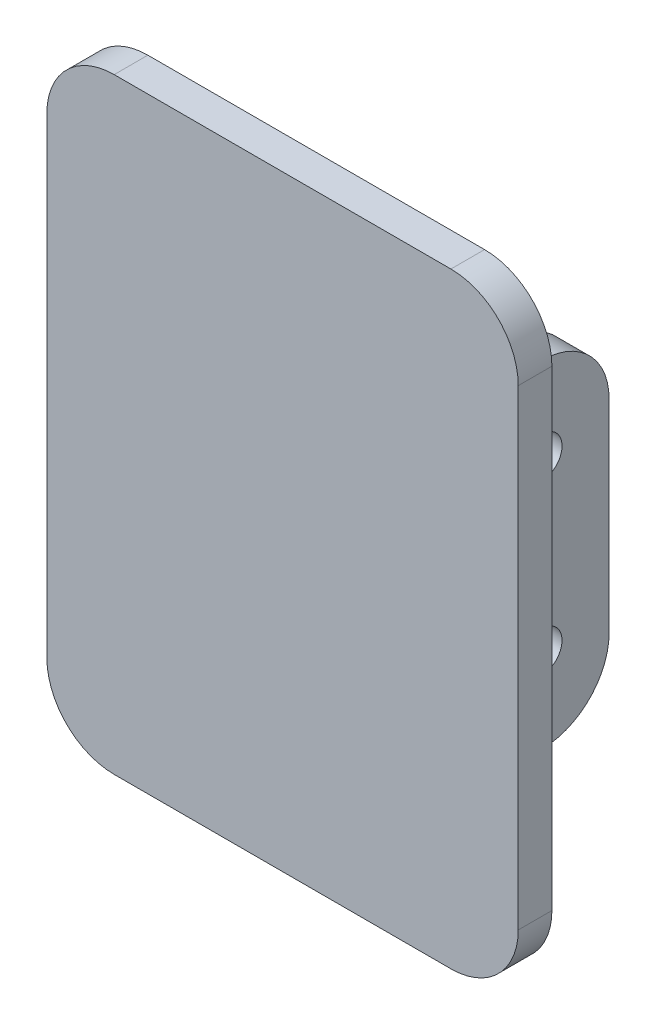
from build123d import *

# Parameters (mm, degrees)
SKETCH1_W           = 70
SKETCH1_H           = 90
BOSS_EXTRUDE1_DEPTH = 5
SKETCH3_W           = 5
SKETCH3_H           = 50
BOSS_EXTRUDE2_DEPTH = 20
SKETCH4_R           = 3
CUT_EXTRUDE1_DEPTH  = 59.5
FILLET1_R           = 3
FILLET2_R           = 10
FILLET3_R           = 10


with BuildPart() as part:
    # Sketch1 → Boss-Extrude1 (new body)
    with BuildSketch(Plane.XY):
        Rectangle(SKETCH1_W, SKETCH1_H)
    extrude(amount=BOSS_EXTRUDE1_DEPTH)

    # Sketch3 → Boss-Extrude2 (add)
    with BuildSketch(Plane(origin=(0, 0, 0), x_dir=(-1, 0, 0), z_dir=(0, 0, -1))):
        with Locations((-1, 0)):
            Rectangle(SKETCH3_W, SKETCH3_H)
        with Locations((-21, 0)):
            Rectangle(SKETCH3_W, SKETCH3_H)
    extrude(amount=BOSS_EXTRUDE2_DEPTH)

    # Sketch4 → Cut-Extrude1 (cut, through all)
    with BuildSketch(Plane(origin=(23.5, 0, 0), x_dir=(0, 0, -1), z_dir=(1, 0, 0))):
        with Locations((10, 12.5)):
            Circle(SKETCH4_R)
        with Locations((10, -12.5)):
            Circle(SKETCH4_R)
    extrude(amount=-CUT_EXTRUDE1_DEPTH, mode=Mode.SUBTRACT)

    # Fillet1
    fillet1_edges = [part.edges().sort_by_distance(p)[0] for p in [
        (21, 25, 0),
        (23.5, 0, 0),
        (21, -25, 0),
        (-1.5, 0, 0),
        (1, 25, 0),
        (1, -25, 0),
    ]]
    fillet(fillet1_edges, radius=FILLET1_R)

    # Fillet2
    fillet2_edges = [part.edges().sort_by_distance(p)[0] for p in [
        (21, 25, -20),
        (21, -25, -20),
        (1, 25, -20),
        (1, -25, -20),
    ]]
    fillet(fillet2_edges, radius=FILLET2_R)

    # Fillet3
    fillet3_edges = [part.edges().sort_by_distance(p)[0] for p in [
        (35, -45, 2.5),
        (-35, -45, 2.5),
        (-35, 45, 2.5),
        (35, 45, 2.5),
    ]]
    fillet(fillet3_edges, radius=FILLET3_R)


solid = part.part
